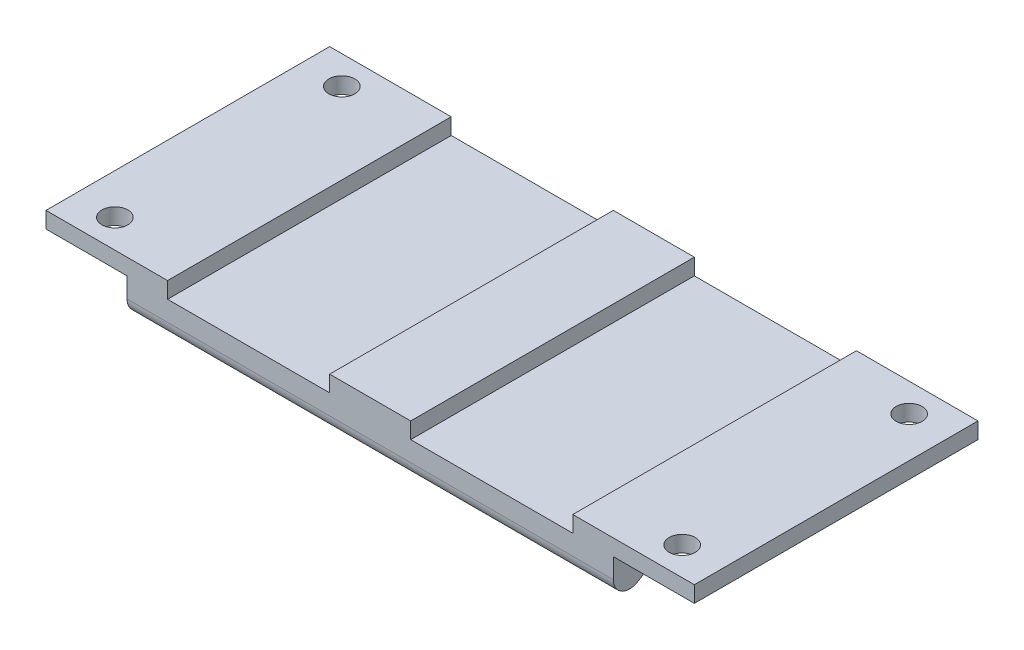
from build123d import *

# Parameters (mm, degrees)
SKETCH1_W               = 60
SKETCH1_H               = 35
BOSS_EXTRUDE1_DEPTH     = 8
CUT_EXTRUDE1_DEPTH      = 1
CUT_EXTRUDE1_DEPTH_BACK = 61
FILLET1_R               = 2
SKETCH3_W               = 20
SKETCH3_H               = 2
CUT_EXTRUDE2_DEPTH      = 36
SKETCH5_W               = 35
SKETCH5_H               = 2
BOSS_EXTRUDE2_DEPTH     = 10
SKETCH6_R               = 1.6
CUT_EXTRUDE3_DEPTH      = 10


with BuildPart() as part:
    # Sketch1 → Boss-Extrude1 (new body)
    with BuildSketch(Plane(origin=(0, 0, 0), x_dir=(1, 0, 0), z_dir=(0, 1, 0))):
        Rectangle(SKETCH1_W, SKETCH1_H)
    extrude(amount=-BOSS_EXTRUDE1_DEPTH)

    # Sketch2 → Cut-Extrude1 (cut, two sides)
    with BuildSketch(Plane(origin=(30, 0, 0), x_dir=(0, 0, -1), z_dir=(1, 0, 0))) as cut_extrude1_sk:
        Polygon((-12.5, -5), (-17.5, -8), (0, -8), (0, -5), align=None)
        Polygon((0, -5), (0, -8), (17.5, -8), (12.5, -5), align=None)
    extrude(amount=CUT_EXTRUDE1_DEPTH, mode=Mode.SUBTRACT)
    extrude(cut_extrude1_sk.sketch, amount=-CUT_EXTRUDE1_DEPTH_BACK, mode=Mode.SUBTRACT)

    # Fillet1
    fillet1_edges = [part.edges().sort_by_distance(p)[0] for p in [
        (0, -8, -17.5),
        (0, -5, 12.5),
        (0, -5, -12.5),
        (0, -8, 17.5),
    ]]
    fillet(fillet1_edges, radius=FILLET1_R)

    # Sketch3 → Cut-Extrude2 (cut, through all)
    with BuildSketch(Plane.XY.offset(17.5)):
        with Locations((-15, -1)):
            Rectangle(SKETCH3_W, SKETCH3_H)
        with Locations((15, -1)):
            Rectangle(SKETCH3_W, SKETCH3_H)
    extrude(amount=-CUT_EXTRUDE2_DEPTH, mode=Mode.SUBTRACT)

    # Sketch5 → Boss-Extrude2 (add)
    with BuildSketch(Plane.ZY.offset(30)):
        with Locations((0, -1)):
            Rectangle(SKETCH5_W, SKETCH5_H)
    boss_extrude2 = extrude(amount=BOSS_EXTRUDE2_DEPTH)

    # Mirror1: Boss-Extrude2 across plane
    add(boss_extrude2.mirror(Plane(origin=(0, 0, 0), x_dir=(0, 0, 1), z_dir=(1, 0, 0))))

    # Sketch6 → Cut-Extrude3 (cut)
    with BuildSketch(Plane(origin=(0, 0, 0), x_dir=(1, 0, 0), z_dir=(0, 1, 0))):
        with Locations((-35, 14)):
            Circle(SKETCH6_R)
        with Locations((35, 14)):
            Circle(SKETCH6_R)
        with Locations((35, -14)):
            Circle(SKETCH6_R)
        with Locations((-35, -14)):
            Circle(SKETCH6_R)
    extrude(amount=-CUT_EXTRUDE3_DEPTH, mode=Mode.SUBTRACT)


solid = part.part
